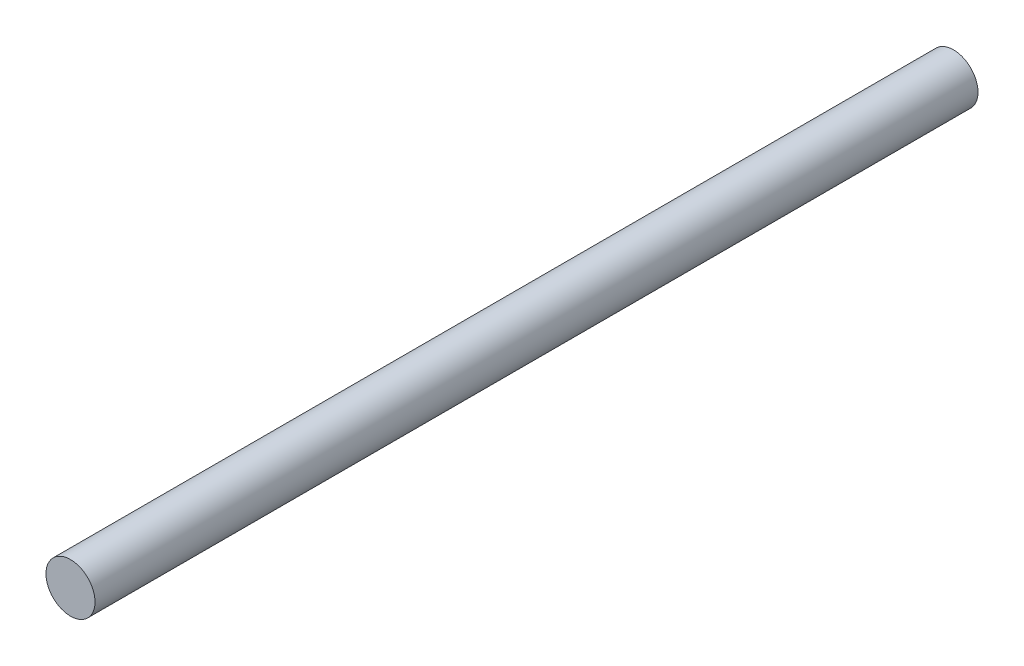
from build123d import *

# Parameters (mm, degrees)
IZIM1_R                     = 5
Y_KSEKLIK_EKSTR_ZYON1_DEPTH = 180


with BuildPart() as part:
    # Çizim1 → Yükseklik-Ekstrüzyon1 (new body)
    with BuildSketch(Plane.XY):
        Circle(IZIM1_R)
    extrude(amount=Y_KSEKLIK_EKSTR_ZYON1_DEPTH)


solid = part.part
